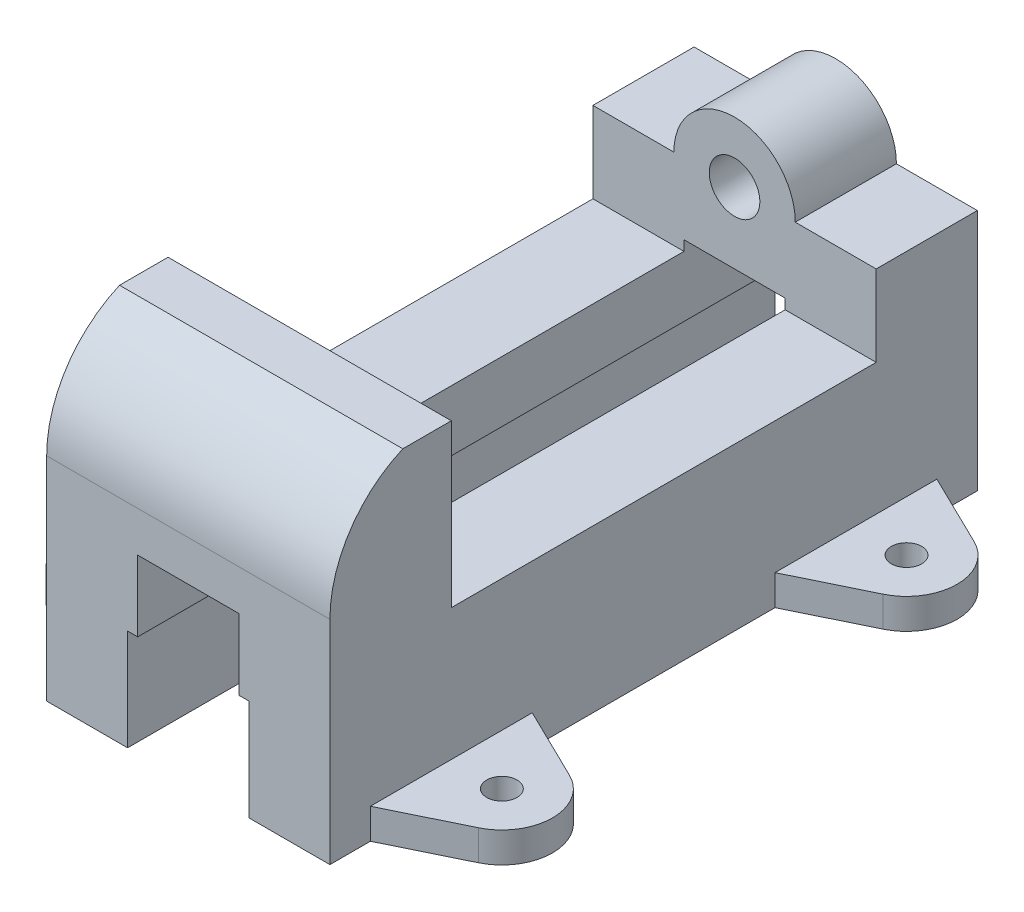
from build123d import *

# Parameters (mm, degrees)
BOSS_EXTRUDE1_DEPTH = 88.9
CUT_EXTRUDE1_DEPTH  = 203.2
BOSS_EXTRUDE2_DEPTH = 31.75
SKETCH5_R           = 7.9375
CUT_EXTRUDE2_DEPTH  = 31.75
SKETCH6_R           = 4.7625
BOSS_EXTRUDE3_DEPTH = 9.525


with BuildPart() as part:
    # Sketch2 → Boss-Extrude1 (new body)
    with BuildSketch(Plane(origin=(0, 0, 0), x_dir=(0, 0, -1), z_dir=(1, 0, 0))):
        with BuildLine():
            Line((0, 0), (0, 66.675))
            ThreePointArc((0, 66.675), (6.227207921, 87.549269451), (22.873234913, 101.6))
            Line((22.873234913, 101.6), (38.1, 101.6))
            Line((38.1, 101.6), (38.1, 50.8))
            Line((38.1, 50.8), (171.45, 50.8))
            Line((171.45, 50.8), (171.45, 76.2))
            Line((171.45, 76.2), (203.2, 76.2))
            Line((203.2, 76.2), (203.2, 0))
            Line((203.2, 0), (171.45, 0))
            Line((171.45, 0), (38.1, 0))
            Line((38.1, 0), (0, 0))
        make_face()
    extrude(amount=BOSS_EXTRUDE1_DEPTH)

    # Sketch3 → Cut-Extrude1 (cut)
    with BuildSketch(Plane(origin=(0, 0, -203.2), x_dir=(-1, 0, 0), z_dir=(0, 0, -1))):
        Polygon((-44.45, 0), (-25.4, 0), (-25.4, 31.75), (-28.575, 31.75), (-28.575, 53.975), (-60.325, 53.975), (-60.325, 31.75), (-63.5, 31.75), (-63.5, 0), align=None)
    extrude(amount=-CUT_EXTRUDE1_DEPTH, mode=Mode.SUBTRACT)

    # Sketch4 → Boss-Extrude2 (add)
    with BuildSketch(Plane(origin=(0, 0, -203.2), x_dir=(-1, 0, 0), z_dir=(0, 0, -1))):
        with BuildLine():
            Line((-63.5, 76.2), (-25.4, 76.2))
            ThreePointArc((-25.4, 76.2), (-44.45, 95.25), (-63.5, 76.2))
        make_face()
    extrude(amount=-BOSS_EXTRUDE2_DEPTH)

    # Sketch5 → Cut-Extrude2 (cut)
    with BuildSketch(Plane(origin=(0, 0, -203.2), x_dir=(-1, 0, 0), z_dir=(0, 0, -1))):
        with Locations((-44.45, 76.2)):
            Circle(SKETCH5_R)
    extrude(amount=-CUT_EXTRUDE2_DEPTH, mode=Mode.SUBTRACT)

    # Sketch6 → Boss-Extrude3 (add)
    with BuildSketch(Plane(origin=(0, 0, 0), x_dir=(1, 0, 0), z_dir=(0, 1, 0))):
        with BuildLine():
            ThreePointArc((-22.831460674, 23.830337079), (-31.75, 38.1), (-22.831460674, 52.369662921))
            Line((-22.831460674, 52.369662921), (0, 63.5))
            Line((0, 63.5), (0, 12.7))
            Line((0, 12.7), (-22.831460674, 23.830337079))
        make_face()
        with Locations((-15.875, 38.1)):
            Circle(SKETCH6_R, mode=Mode.SUBTRACT)
        with BuildLine():
            ThreePointArc((-22.831460674, 150.830337079), (-31.75, 165.1), (-22.831460674, 179.369662921))
            Line((-22.831460674, 179.369662921), (0, 190.5))
            Line((0, 190.5), (0, 139.7))
            Line((0, 139.7), (-22.831460674, 150.830337079))
        make_face()
        with Locations((-15.875, 165.1)):
            Circle(SKETCH6_R, mode=Mode.SUBTRACT)
        with BuildLine():
            Line((88.9, 139.7), (111.731460674, 150.830337079))
            ThreePointArc((111.731460674, 150.830337079), (120.65, 165.1), (111.731460674, 179.369662921))
            Line((111.731460674, 179.369662921), (88.9, 190.5))
            Line((88.9, 190.5), (88.9, 139.7))
        make_face()
        with Locations((104.775, 165.1)):
            Circle(SKETCH6_R, mode=Mode.SUBTRACT)
        with BuildLine():
            Line((88.9, 12.7), (111.731460674, 23.830337079))
            ThreePointArc((111.731460674, 23.830337079), (120.65, 38.1), (111.731460674, 52.369662921))
            Line((111.731460674, 52.369662921), (88.9, 63.5))
            Line((88.9, 63.5), (88.9, 12.7))
        make_face()
        with Locations((104.775, 38.1)):
            Circle(SKETCH6_R, mode=Mode.SUBTRACT)
    extrude(amount=BOSS_EXTRUDE3_DEPTH)


solid = part.part
